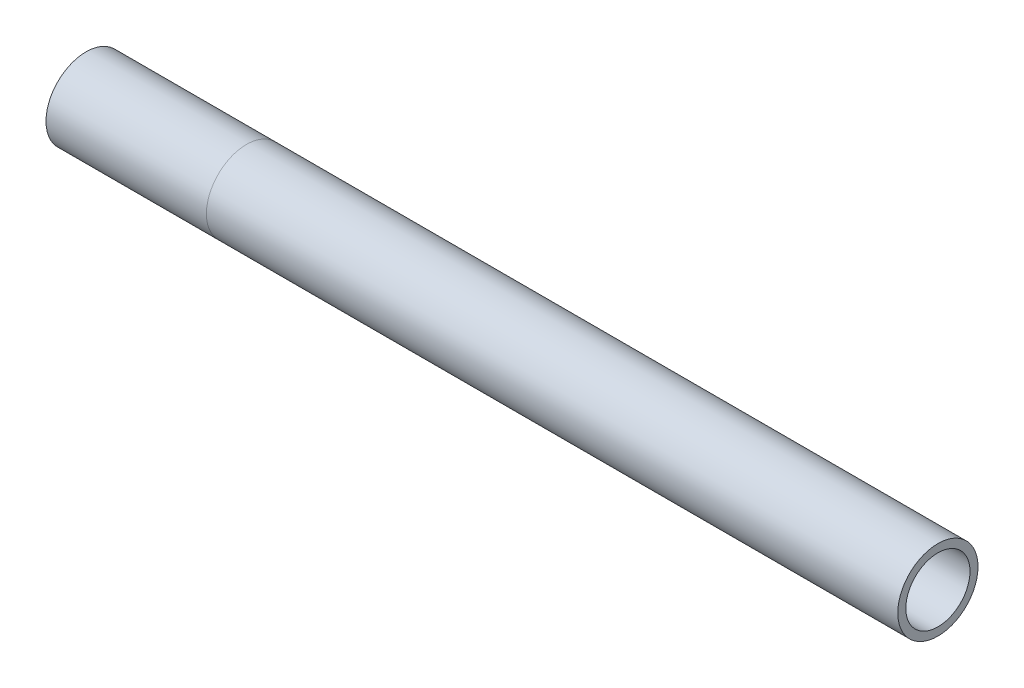
from build123d import *

# Parameters (mm, degrees)
SKETCH1_R                = 12.7
SKETCH1_R_2              = 10.16
TUBING_TUBING_1_DEPTH    = 50.8
SKETCH1_ON_SEGMENT_2_R   = 12.7
SKETCH1_ON_SEGMENT_2_R_2 = 10.16
TUBING_TUBING_1_2_DEPTH  = 218.948


with BuildPart() as part:
    # Sketch1 → Tubing TUBING(1) (new body)
    with BuildSketch(Plane(origin=(-107.318138062, 25.893490854, 0), x_dir=(0, 1, 0), z_dir=(1, 0, 0))):
        Circle(SKETCH1_R)
        Circle(SKETCH1_R_2, mode=Mode.SUBTRACT)
    extrude(amount=TUBING_TUBING_1_DEPTH)


with BuildPart() as body_2:
    # Sketch1 on segment 2 (carried to segment 2) → Tubing TUBING_1 2 (new body)
    with BuildSketch(Plane(origin=(-56.518138062, 25.893490854, 0), x_dir=(0, 1, 0), z_dir=(1, 0, 0))):
        Circle(SKETCH1_ON_SEGMENT_2_R)
        Circle(SKETCH1_ON_SEGMENT_2_R_2, mode=Mode.SUBTRACT)
    extrude(amount=TUBING_TUBING_1_2_DEPTH)


solid = Compound([part.part, body_2.part])
